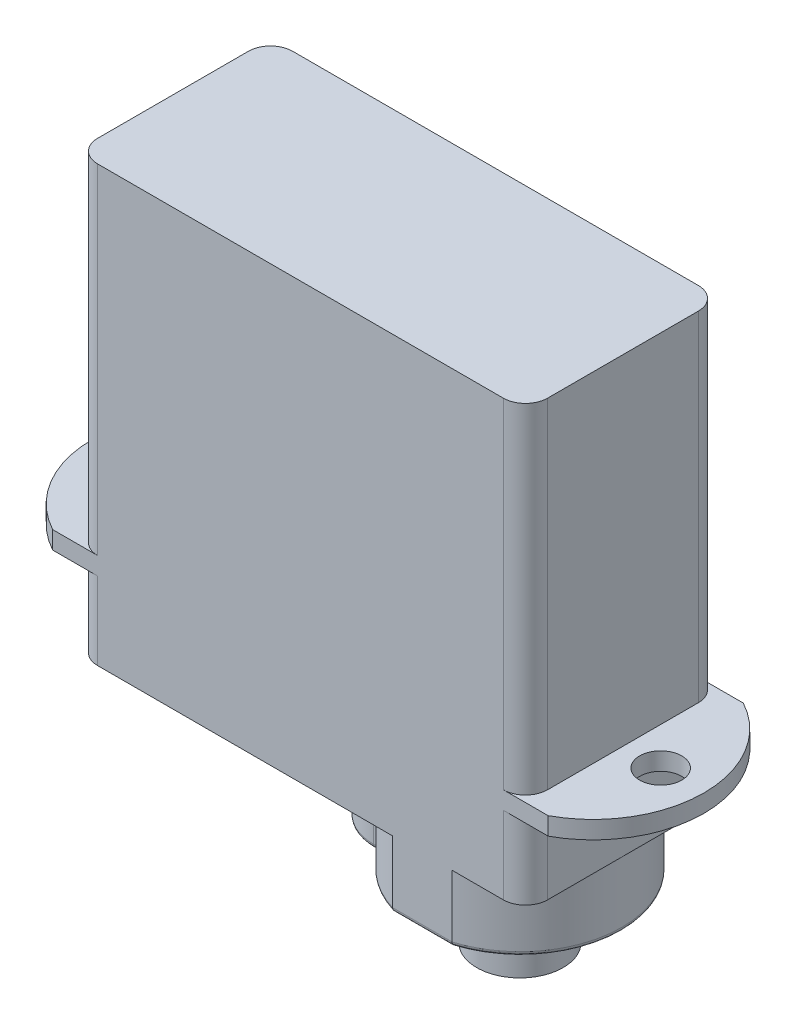
from build123d import *

# Parameters (mm, degrees)
EXTRUDE_1_DEPTH     = 19.6
EXTRUDE_START       = -3.5
EXTRUDE_2_DEPTH     = 0.8
EXTRUDE_3_DEPTH     = 3
FILLET_1_R          = 0.2
SKETCH_4_R          = 1.95
SKETCH_4_R_2        = 0.75
EXTRUDE_4_DEPTH     = 2.7
CUT_EXTRUDE_1_REACH = 18.1
SKETCH_5_R          = 0.95


with BuildPart() as part:
    # Эскиз1 → Бобышка-Вытянуть1 (new body)
    with BuildSketch(Plane(origin=(0, 0, 0), x_dir=(1, 0, 0), z_dir=(0, 1, 0))):
        with BuildLine():
            Line((-9.15, -4.4), (9.15, -4.4))
            ThreePointArc((9.15, -4.4), (9.857106781, -4.107106781), (10.15, -3.4))
            Line((10.15, -3.4), (10.15, 3.4))
            ThreePointArc((10.15, 3.4), (9.857106781, 4.107106781), (9.15, 4.4))
            Line((9.15, 4.4), (-9.15, 4.4))
            ThreePointArc((-9.15, 4.4), (-9.857106781, 4.107106781), (-10.15, 3.4))
            Line((-10.15, 3.4), (-10.15, -3.4))
            ThreePointArc((-10.15, -3.4), (-9.857106781, -4.107106781), (-9.15, -4.4))
        make_face()
    extrude(amount=EXTRUDE_1_DEPTH)

    # Эскиз2 → Бобышка-Вытянуть2 (add)
    with BuildSketch(Plane.XZ.offset(EXTRUDE_START)):
        with BuildLine():
            Line((-9.15, 4.4), (-11.174868417, 4.4))
            ThreePointArc((-11.174868417, 4.4), (-13.8, 0), (-11.174868417, -4.4))
            Line((-11.174868417, -4.4), (-9.15, -4.4))
            ThreePointArc((-9.15, -4.4), (-9.857106781, -4.107106781), (-10.15, -3.4))
            Line((-10.15, -3.4), (-10.15, 3.4))
            ThreePointArc((-10.15, 3.4), (-9.857106781, 4.107106781), (-9.15, 4.4))
        make_face()
        with BuildLine():
            Line((11.174868417, 4.4), (9.15, 4.4))
            ThreePointArc((9.15, 4.4), (9.857106781, 4.107106781), (10.15, 3.4))
            Line((10.15, 3.4), (10.15, -3.4))
            ThreePointArc((10.15, -3.4), (9.857106781, -4.107106781), (9.15, -4.4))
            Line((9.15, -4.4), (11.174868417, -4.4))
            ThreePointArc((11.174868417, -4.4), (13.8, 0), (11.174868417, 4.4))
        make_face()
    extrude(amount=-EXTRUDE_2_DEPTH)

    # Эскиз3 → Бобышка-Вытянуть3 (add)
    with BuildSketch(Plane.XZ):
        with BuildLine():
            ThreePointArc((4.158359214, 4.4), (2.660508694, 3.619017701), (1.545572102, 2.35))
            Line((1.545572102, 2.35), (1.25, 2.35))
            ThreePointArc((1.25, 2.35), (-1.1, 0), (1.25, -2.35))
            Line((1.25, -2.35), (1.545572102, -2.35))
            ThreePointArc((1.545572102, -2.35), (2.660508694, -3.619017701), (4.158359214, -4.4))
            Line((4.158359214, -4.4), (6.841640786, -4.4))
            ThreePointArc((6.841640786, -4.4), (10.1, 0), (6.841640786, 4.4))
            Line((6.841640786, 4.4), (4.158359214, 4.4))
        make_face()
    extrude(amount=EXTRUDE_3_DEPTH)

    # Скругление1
    fillet_1_edges = [part.edges().sort_by_distance(p)[0] for p in [
        (-1.1, -3, 0),
        (2.660508694, -3, -3.619017701),
        (5.5, -3, -4.4),
        (10.1, -3, 0),
        (5.5, -3, 4.4),
        (2.660508694, -3, 3.619017701),
        (1.397786051, -3, -2.35),
        (1.397786051, -3, 2.35),
    ]]
    fillet(fillet_1_edges, radius=FILLET_1_R)

    # Эскиз4 → Бобышка-Вытянуть4 (add)
    with BuildSketch(Plane.XZ.offset(3)):
        with Locations((5.5, 0)):
            Circle(SKETCH_4_R)
        with Locations((5.5, 0)):
            Circle(SKETCH_4_R_2, mode=Mode.SUBTRACT)
    extrude(amount=EXTRUDE_4_DEPTH)

    # Эскиз5 → Вырез-Вытянуть1 (cut, up to next)
    with BuildSketch(Plane.XZ.offset(-3.5), mode=Mode.PRIVATE) as cut_extrude_1_sk1:
        with Locations((-11.85, 0)):
            Circle(SKETCH_5_R)
    cut_extrude_1_tool1 = extrude(cut_extrude_1_sk1.sketch, amount=-CUT_EXTRUDE_1_REACH, mode=Mode.PRIVATE) & part.part
    add(cut_extrude_1_tool1.solids().sort_by_distance((-11.85, 3.5, 0))[0], mode=Mode.SUBTRACT)
    # Эскиз5 → Вырез-Вытянуть1 (cut, up to next)
    with BuildSketch(Plane.XZ.offset(-3.5), mode=Mode.PRIVATE) as cut_extrude_1_sk2:
        with Locations((11.85, 0)):
            Circle(SKETCH_5_R)
    cut_extrude_1_tool2 = extrude(cut_extrude_1_sk2.sketch, amount=-CUT_EXTRUDE_1_REACH, mode=Mode.PRIVATE) & part.part
    add(cut_extrude_1_tool2.solids().sort_by_distance((11.85, 3.5, 0))[0], mode=Mode.SUBTRACT)


solid = part.part
